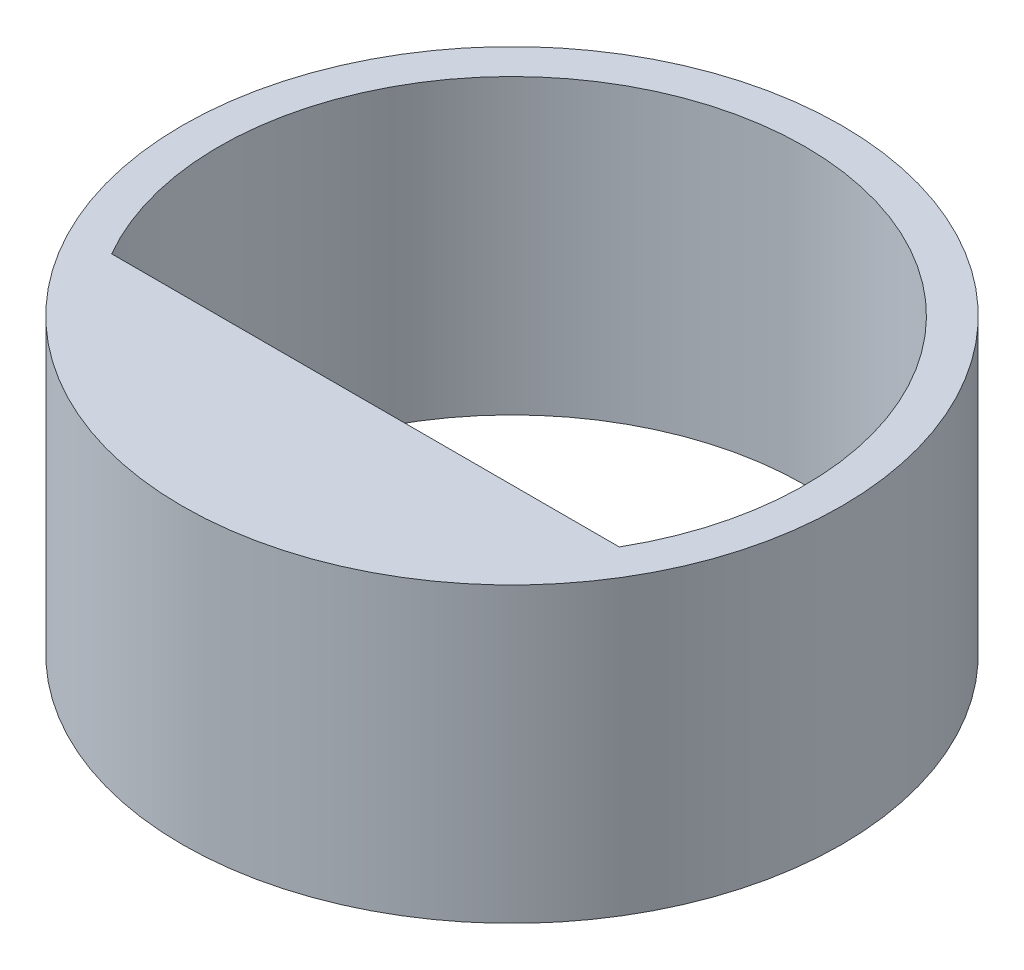
from build123d import *

# Parameters (mm, degrees)
SKETCH1_R           = 2.25
BOSS_EXTRUDE1_DEPTH = 2


with BuildPart() as part:
    # Sketch1 → Boss-Extrude1 (new body)
    with BuildSketch(Plane(origin=(0, 0, 0), x_dir=(1, 0, 0), z_dir=(0, 1, 0))):
        Circle(SKETCH1_R)
        with BuildLine():
            Line((-1.732050808, -1), (1.732050808, -1))
            ThreePointArc((1.732050808, -1), (0, 2), (-1.732050808, -1))
        make_face(mode=Mode.SUBTRACT)
    extrude(amount=BOSS_EXTRUDE1_DEPTH)


solid = part.part
